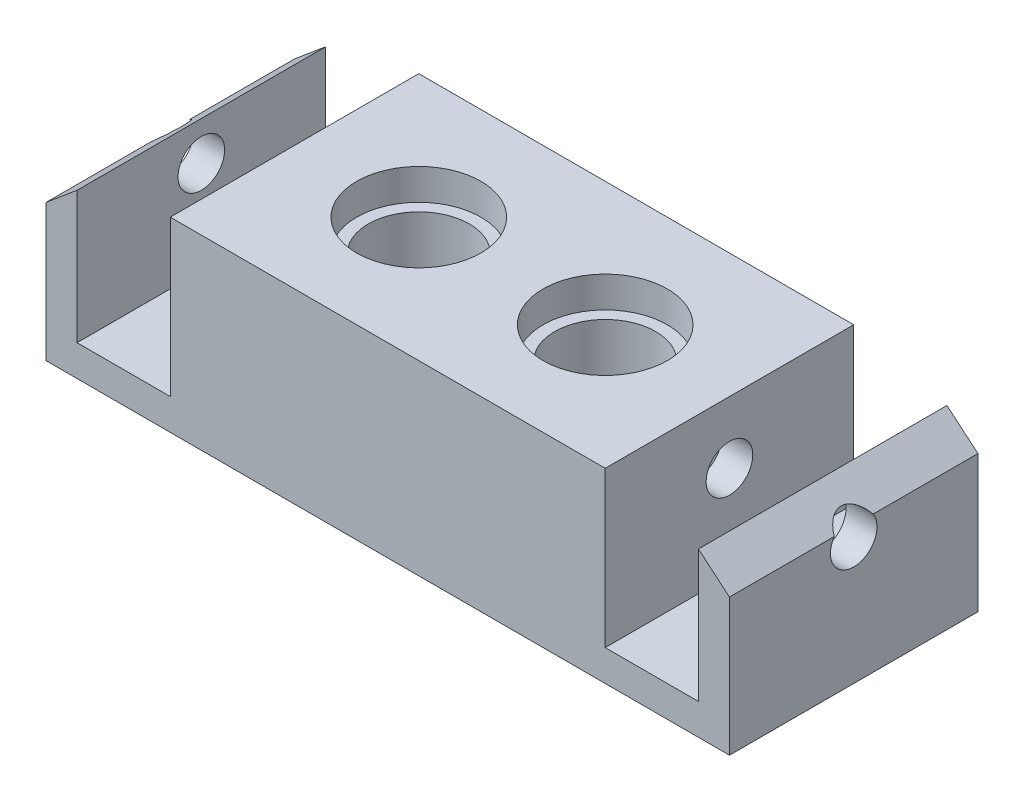
from build123d import *

# Parameters (mm, degrees)
SKETCH1_W             = 22
SKETCH1_H             = 6
BOSS_EXTRUDE1_DEPTH   = 8
SKETCH2_W             = 12
SKETCH2_H             = 6
CUT_EXTRUDE1_DEPTH    = 5
SKETCH3_R             = 2.5
SKETCH3_R_2           = 1.625
BOSS_EXTRUDE4_DEPTH   = 2
BOSS_EXTRUDE4_2_DEPTH = 2
SKETCH5_R             = 2
CUT_EXTRUDE3_DEPTH    = 1
SKETCH6_W             = 3
SKETCH6_H             = 5
CUT_EXTRUDE4_DEPTH    = 9
SKETCH8_R             = 0.75
CUT_EXTRUDE6_DEPTH    = 5.5
CUT_EXTRUDE7_DEPTH    = 10


with BuildPart() as part:
    # Sketch1 → Boss-Extrude1 (new body)
    with BuildSketch(Plane.XY):
        with Locations((11, 3)):
            Rectangle(SKETCH1_W, SKETCH1_H)
    extrude(amount=-BOSS_EXTRUDE1_DEPTH)

    # Sketch2 → Cut-Extrude1 (cut)
    with BuildSketch(Plane.XZ):
        with Locations((11, -4)):
            Rectangle(SKETCH2_W, SKETCH2_H)
    extrude(amount=-CUT_EXTRUDE1_DEPTH, mode=Mode.SUBTRACT)

    # Sketch5 → Cut-Extrude3 (cut)
    with BuildSketch(Plane(origin=(0, 6, 0), x_dir=(1, 0, 0), z_dir=(0, 1, 0))):
        with Locations((8, 4)):
            Circle(SKETCH5_R)
        with Locations((14, 4)):
            Circle(SKETCH5_R)
    extrude(amount=-CUT_EXTRUDE3_DEPTH, mode=Mode.SUBTRACT)

    # Sketch6 → Cut-Extrude4 (cut, through all)
    with BuildSketch(Plane.XY):
        with Locations((2.5, 3.5)):
            Rectangle(SKETCH6_W, SKETCH6_H)
        with Locations((19.5, 3.5)):
            Rectangle(SKETCH6_W, SKETCH6_H)
    extrude(amount=-CUT_EXTRUDE4_DEPTH, mode=Mode.SUBTRACT)

    # Sketch8 → Cut-Extrude6 (cut)
    with BuildSketch(Plane(origin=(22, 0, 0), x_dir=(0, 0, -1), z_dir=(1, 0, 0))):
        with Locations((4, 4)):
            Circle(SKETCH8_R)
    cut_extrude6 = extrude(amount=-CUT_EXTRUDE6_DEPTH, mode=Mode.SUBTRACT)

    # Mirror1: Cut-Extrude6 across plane
    add(cut_extrude6.mirror(Plane(origin=(11, 0, 0), x_dir=(0, 0, 1), z_dir=(1, 0, 0))), mode=Mode.SUBTRACT)

    # Sketch9 → Cut-Extrude7 (cut)
    with BuildSketch(Plane.XY):
        Polygon((21, 6), (22, 6), (22, 4.410900369), (21, 5.25), align=None)
    cut_extrude7 = extrude(amount=-CUT_EXTRUDE7_DEPTH, mode=Mode.SUBTRACT)

    # Mirror2: Cut-Extrude7 across plane
    add(cut_extrude7.mirror(Plane(origin=(11, 0, 0), x_dir=(0, 0, 1), z_dir=(1, 0, 0))), mode=Mode.SUBTRACT)


with BuildPart() as body_2:
    # Sketch3 → Boss-Extrude4 (new body)
    with BuildSketch(Plane.XZ.offset(-5)):
        with Locations((8, -4)):
            Circle(SKETCH3_R)
        with Locations((8, -4)):
            Circle(SKETCH3_R_2, mode=Mode.SUBTRACT)
    extrude(amount=BOSS_EXTRUDE4_DEPTH)


with BuildPart() as body_3:
    # Sketch3 → Boss-Extrude4 2 (new body)
    with BuildSketch(Plane.XZ.offset(-5)):
        with Locations((14, -4)):
            Circle(SKETCH3_R)
        with Locations((14, -4)):
            Circle(SKETCH3_R_2, mode=Mode.SUBTRACT)
    extrude(amount=BOSS_EXTRUDE4_2_DEPTH)


solid = Compound([part.part, body_2.part, body_3.part])
